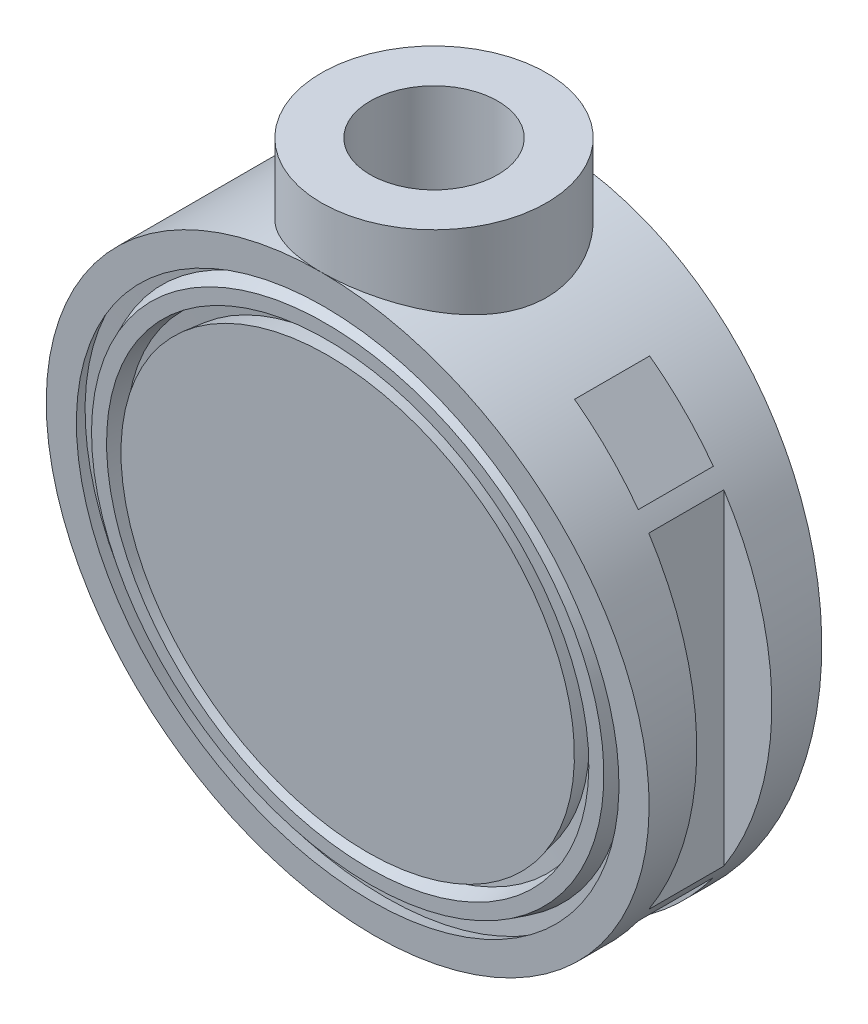
from build123d import *

# Parameters (mm, degrees)
SKETCH1_W                            = 47.625
SKETCH1_H                            = 63.5
CUT_EXTRUDE1_REACH                   = 94.906
CUT_EXTRUDE1_DIRECTION_2_REACH       = 94.906
SKETCH5_R                            = 23.8125
SKETCH5_R_2                          = 13.49375
BOSS_EXTRUDE1_DEPTH                  = 12.7
BOSS_EXTRUDE1_DIRECTION_2_REACH      = 145.973
BOSS_EXTRUDE1_DIRECTION_2_END_RADIUS = 63.5
CUT_EXTRUDE6_DEPTH                   = 7.9375


with BuildPart() as part:
    # Sketch1 → Revolve1 (revolve)
    with BuildSketch(Plane(origin=(0, 0, 0), x_dir=(0, 0, -1), z_dir=(1, 0, 0)), mode=Mode.PRIVATE) as revolve1_sk:
        with Locations((0, 31.75)):
            Rectangle(SKETCH1_W, SKETCH1_H)
    revolve(revolve1_sk.sketch.rotate(Axis((0, 0, 23.8125), (0, 0, -1)), 90), axis=Axis((0, 0, 23.8125), (0, 0, -1)))

    # Sketch2 → Cut-Extrude1 (cut, up to next)
    with BuildSketch(Plane(origin=(0, 0, 0), x_dir=(0, 0, -1), z_dir=(1, 0, 0)), mode=Mode.PRIVATE) as cut_extrude1_sk1:
        Polygon((-12.7, -63.5), (-23.8125, 63.5), (-23.8125, -63.5), align=None)
    cut_extrude1_tool1 = extrude(cut_extrude1_sk1.sketch, amount=-CUT_EXTRUDE1_REACH, mode=Mode.PRIVATE) & part.part
    # Sketch2 → Cut-Extrude1 (cut, up to next)
    with BuildSketch(Plane(origin=(0, 0, 0), x_dir=(0, 0, -1), z_dir=(1, 0, 0)), mode=Mode.PRIVATE) as cut_extrude1_sk2:
        Polygon((23.8125, 63.5), (12.7, -63.5), (23.8125, -63.5), align=None)
    cut_extrude1_tool2 = extrude(cut_extrude1_sk2.sketch, amount=-CUT_EXTRUDE1_REACH, mode=Mode.PRIVATE) & part.part
    add(cut_extrude1_tool1.solids().sort_by_distance((0, -21.166667, 20.108333))[0], mode=Mode.SUBTRACT)
    add(cut_extrude1_tool2.solids().sort_by_distance((0, -21.166667, -20.108333))[0], mode=Mode.SUBTRACT)

    # Sketch2 → Cut-Extrude1 direction 2 (cut, up to next)
    with BuildSketch(Plane(origin=(0, 0, 0), x_dir=(0, 0, -1), z_dir=(1, 0, 0)), mode=Mode.PRIVATE) as cut_extrude1_direction_2_sk1:
        Polygon((-12.7, -63.5), (-23.8125, 63.5), (-23.8125, -63.5), align=None)
    cut_extrude1_direction_2_tool1 = extrude(cut_extrude1_direction_2_sk1.sketch, amount=CUT_EXTRUDE1_DIRECTION_2_REACH, mode=Mode.PRIVATE) & part.part
    # Sketch2 → Cut-Extrude1 direction 2 (cut, up to next)
    with BuildSketch(Plane(origin=(0, 0, 0), x_dir=(0, 0, -1), z_dir=(1, 0, 0)), mode=Mode.PRIVATE) as cut_extrude1_direction_2_sk2:
        Polygon((23.8125, 63.5), (12.7, -63.5), (23.8125, -63.5), align=None)
    cut_extrude1_direction_2_tool2 = extrude(cut_extrude1_direction_2_sk2.sketch, amount=CUT_EXTRUDE1_DIRECTION_2_REACH, mode=Mode.PRIVATE) & part.part
    add(cut_extrude1_direction_2_tool1.solids().sort_by_distance((0, -21.166667, 20.108333))[0], mode=Mode.SUBTRACT)
    add(cut_extrude1_direction_2_tool2.solids().sort_by_distance((0, -21.166667, -20.108333))[0], mode=Mode.SUBTRACT)

    # Sketch3 → Cut-Revolve1 (revolve, cut)
    with BuildSketch(Plane(origin=(0, 0, 0), x_dir=(0, 0, -1), z_dir=(1, 0, 0))):
        Polygon((-14.093252917, -47.577109525), (-13.828168926, -50.606640849), (-10.288822106, -49.658275727), (-10.288822106, -46.557715362), align=None)
        Polygon((-13.552471291, -53.757470955), (-13.274658791, -56.932470955), (-10.288822106, -57.732523484), (-10.288822106, -54.631963119), align=None)
    revolve(axis=Axis((0, 0, 18.25625), (0, 0.08716695028091019, -0.9961937174961131)), mode=Mode.SUBTRACT)

    # Sketch3_4 → Cut-Revolve2 (revolve, cut)
    with BuildSketch(Plane(origin=(0, 0, 0), x_dir=(0, 0, -1), z_dir=(1, 0, 0)), mode=Mode.PRIVATE) as cut_revolve2_sk:
        Polygon((13.274658791, -56.932470955), (13.552471291, -53.757470955), (10.288822106, -54.631963119), (10.288822106, -57.732523484), align=None)
        Polygon((14.093252917, -47.577109525), (10.288822106, -46.557715362), (10.288822106, -49.658275727), (13.828168926, -50.606640849), align=None)
    revolve(cut_revolve2_sk.sketch.rotate(Axis((0, 0, -18.25625), (0, 0.08716695028091019, 0.9961937174961131)), 180), axis=Axis((0, 0, -18.25625), (0, 0.08716695028091019, 0.9961937174961131)), mode=Mode.SUBTRACT)

    # Sketch4 → Cut-Revolve3 (revolve, cut)
    with BuildSketch(Plane(origin=(0, 0, 0), x_dir=(0, 0, -1), z_dir=(1, 0, 0))):
        with BuildLine():
            Line((0, 63.5), (0, -63.5))
            Line((0, -63.5), (-9.525, -63.5))
            Line((-9.525, -63.5), (-6.35, -60.325))
            Line((-6.35, -60.325), (-6.35, -46.667360082))
            Line((-6.35, -46.667360082), (-7.9375, -45.079860082))
            Line((-7.9375, -45.079860082), (-15.65055133, 43.069297973))
            ThreePointArc((-15.65055133, 43.069297973), (-15.321732353, 44.037994297), (-14.385385309, 44.45))
            Line((-14.385385309, 44.45), (-13.49375, 44.45))
            Line((-13.49375, 44.45), (-13.49375, 76.2))
            Line((-13.49375, 76.2), (0, 76.2))
            Line((0, 76.2), (0, 63.5))
        make_face()
    revolve(axis=Axis((0, 63.5, 0), (0, -1, 0)), mode=Mode.SUBTRACT)


with BuildPart() as boss_extrude1_tool:
    # Sketch5 → Boss-Extrude1 (new body)
    with BuildSketch(Plane(origin=(0, 63.5, 0), x_dir=(1, 0, 0), z_dir=(0, 1, 0))):
        with Locations(Location((0, 0, 0), (0, 0, 270))):
            Circle(SKETCH5_R)
        with Locations(Location((0, 0, 0), (0, 0, 270))):
            Circle(SKETCH5_R_2, mode=Mode.SUBTRACT)
    extrude(amount=BOSS_EXTRUDE1_DEPTH)


with BuildPart() as part_1:
    add(part.part)


with BuildPart() as part_2:
    # Boss-Extrude1: joined with boss_extrude1_tool
    add(part_1.part.fuse(boss_extrude1_tool.part, tol=0.00001))

    # Boss-Extrude1 direction 2: up to this cylinder (the profile starts outside it)
    boss_extrude1_direction_2_end = Plane(origin=(0, 0, -23.138981), z_dir=(0, 0, 1)) * Cylinder(BOSS_EXTRUDE1_DIRECTION_2_END_RADIUS, 419.946, mode=Mode.PRIVATE)
    # Sketch5 → Boss-Extrude1 direction 2 (add, up to the surface)
    with BuildSketch(Plane(origin=(0, 63.5, 0), x_dir=(1, 0, 0), z_dir=(0, 1, 0)), mode=Mode.PRIVATE) as boss_extrude1_direction_2_sk1:
        with Locations(Location((0, 0, 0), (0, 0, 270))):
            Circle(SKETCH5_R)
        with Locations(Location((0, 0, 0), (0, 0, 270))):
            Circle(SKETCH5_R_2, mode=Mode.SUBTRACT)
    boss_extrude1_direction_2_tool1 = extrude(boss_extrude1_direction_2_sk1.sketch, amount=-BOSS_EXTRUDE1_DIRECTION_2_REACH, mode=Mode.PRIVATE) - boss_extrude1_direction_2_end
    add(boss_extrude1_direction_2_tool1.solids().sort_by_distance((0, 63.5, -23.138981))[0])
    add(boss_extrude1_direction_2_tool1.solids().sort_by_distance((0, 63.5, -23.138981))[1])

    # Sketch6 → Cut-Extrude6 (cut, symmetric)
    with BuildSketch(Plane.XY):
        Polygon((0, 27.783421303), (0, -50.606640849), (6.35, -50.401562476), (6.35, -46.667360082), (7.9375, -45.079860082), (14.313037121, 27.783421303), align=None)
        with BuildLine():
            ThreePointArc((28.548758758, -42.01914294), (17.945670231, -47.524655916), (6.35, -50.401562476))
            Line((6.35, -50.401562476), (6.35, -46.667360082))
            Line((6.35, -46.667360082), (7.9375, -45.079860082))
            Line((7.9375, -45.079860082), (14.313037121, 27.783421303))
            Line((14.313037121, 27.783421303), (37.658075276, 51.128459458))
            Line((37.658075276, 51.128459458), (46.638331397, 60.108715579))
            Line((46.638331397, 60.108715579), (60.108715579, 46.638331397))
            Line((60.108715579, 46.638331397), (51.128459458, 37.658075276))
            Line((51.128459458, 37.658075276), (44.74493597, 31.274551788))
            ThreePointArc((44.74493597, 31.274551788), (44.056682484, 30.244507656), (43.815, 29.029487758))
            Line((43.815, 29.029487758), (43.815, 25.425127265))
            ThreePointArc((43.815, 25.425127265), (43.279916019, 23.661191775), (41.855019898, 22.491809749))
            Line((41.855019898, 22.491809749), (32.467470153, 18.603359327))
            ThreePointArc((32.467470153, 18.603359327), (29.890023726, 12.380853207), (36.112529847, 9.80340678))
            Line((36.112529847, 9.80340678), (39.424980102, 11.175468601))
            ThreePointArc((39.424980102, 11.175468601), (42.40393549, 10.882067104), (43.815, 8.242151085))
            Line((43.815, 8.242151085), (43.815, -8.242151085))
            ThreePointArc((43.815, -8.242151085), (42.40393549, -10.882067104), (39.424980102, -11.175468601))
            Line((39.424980102, -11.175468601), (36.112529847, -9.80340678))
            ThreePointArc((36.112529847, -9.80340678), (29.890023726, -12.380853207), (32.467470153, -18.603359327))
            Line((32.467470153, -18.603359327), (41.855019898, -22.491809749))
            ThreePointArc((41.855019898, -22.491809749), (43.279916019, -23.661191775), (43.815, -25.425127265))
            Line((43.815, -25.425127265), (43.815, -29.029487758))
            ThreePointArc((43.815, -29.029487758), (44.056682484, -30.244507656), (44.74493597, -31.274551788))
            Line((44.74493597, -31.274551788), (51.128459458, -37.658075276))
            Line((51.128459458, -37.658075276), (60.108715579, -46.638331397))
            Line((60.108715579, -46.638331397), (46.638331397, -60.108715579))
            Line((46.638331397, -60.108715579), (37.658075276, -51.128459458))
            Line((37.658075276, -51.128459458), (28.548758758, -42.01914294))
        make_face()
        with BuildLine():
            ThreePointArc((15.08125, -22.225), (19.05, -26.19375), (23.01875, -22.225))
            Line((23.01875, -22.225), (23.01875, 22.225))
            ThreePointArc((23.01875, 22.225), (19.05, 26.19375), (15.08125, 22.225))
            Line((15.08125, 22.225), (15.08125, -22.225))
        make_face(mode=Mode.SUBTRACT)
        with BuildLine():
            ThreePointArc((53.34, -34.454236314), (63.5, 0), (53.34, 34.454236314))
            Line((53.34, 34.454236314), (53.34, -34.454236314))
        make_face()
    extrude(amount=CUT_EXTRUDE6_DEPTH, both=True, mode=Mode.SUBTRACT)


solid = part_2.part
